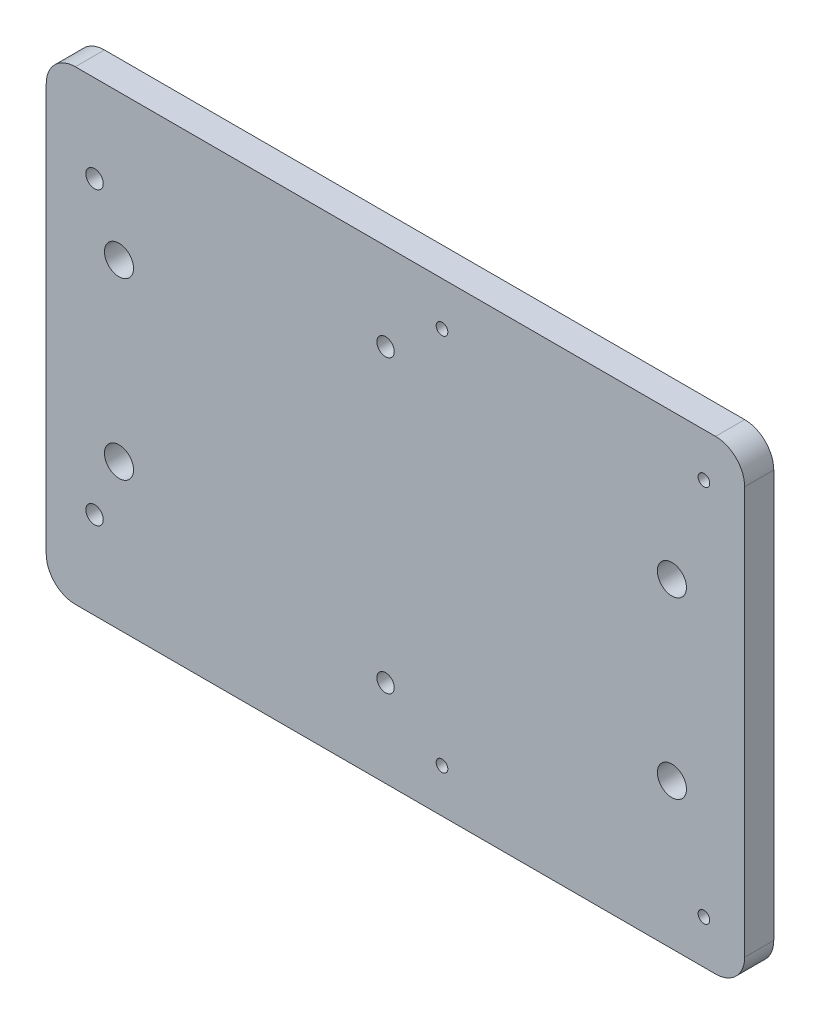
from build123d import *

# Parameters (mm, degrees)
SKETCH_1_W          = 120
SKETCH_1_H          = 80
SKETCH_1_R          = 2.5
EXTRUDE_1_DEPTH     = 5
SKETCH_3_R          = 1.5
SKETCH_3_R_2        = 1
CUT_EXTRUDE_1_DEPTH = 10
FILLET_1_R          = 5


with BuildPart() as part:
    # 草图1 → 凸台-拉伸1 (new body)
    with BuildSketch(Plane.XY):
        Rectangle(SKETCH_1_W, SKETCH_1_H)
        with Locations((-47.5, 15)):
            Circle(SKETCH_1_R, mode=Mode.SUBTRACT)
        with Locations((47.5, 15)):
            Circle(SKETCH_1_R, mode=Mode.SUBTRACT)
        with Locations((47.5, -15)):
            Circle(SKETCH_1_R, mode=Mode.SUBTRACT)
        with Locations((-47.5, -15)):
            Circle(SKETCH_1_R, mode=Mode.SUBTRACT)
    extrude(amount=EXTRUDE_1_DEPTH)

    # 草图3 → 切除-拉伸1 (cut)
    with BuildSketch(Plane(origin=(0, 0, 0), x_dir=(-1, 0, 0), z_dir=(0, 0, -1))):
        with Locations((51.702251253, -25)):
            Circle(SKETCH_3_R)
        with Locations((1.702251253, -25)):
            Circle(SKETCH_3_R)
        with Locations((1.702251253, 25)):
            Circle(SKETCH_3_R)
        with Locations((51.702251253, 25)):
            Circle(SKETCH_3_R)
        with Locations((-8, -32.5)):
            Circle(SKETCH_3_R_2)
        with Locations((-53, -32.5)):
            Circle(SKETCH_3_R_2)
        with Locations((-53, 32.5)):
            Circle(SKETCH_3_R_2)
        with Locations((-8, 32.5)):
            Circle(SKETCH_3_R_2)
    extrude(amount=-CUT_EXTRUDE_1_DEPTH, mode=Mode.SUBTRACT)

    # 圆角1
    fillet_1_edges = [part.edges().sort_by_distance(p)[0] for p in [
        (60, -40, 2.5),
        (-60, -40, 2.5),
        (-60, 40, 2.5),
        (60, 40, 2.5),
    ]]
    fillet(fillet_1_edges, radius=FILLET_1_R)


solid = part.part
